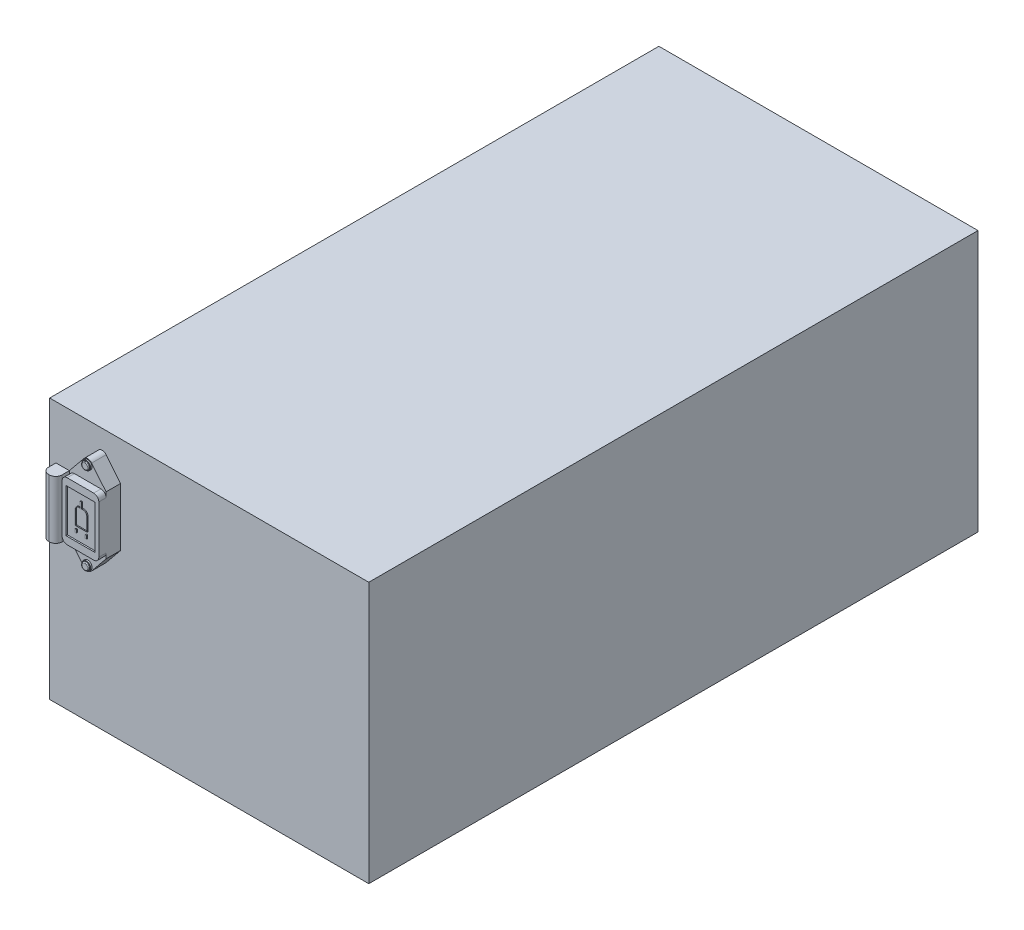
from build123d import *

# Parameters (mm, degrees)
SKETCH1_W           = 220
SKETCH1_H           = 180
BOSS_EXTRUDE1_DEPTH = 420
BOSS_EXTRUDE2_DEPTH = 10
BOSS_EXTRUDE3_DEPTH = 5
SKETCH4_R           = 3
BOSS_EXTRUDE4_DEPTH = 1
SKETCH5_R           = 2.5
BOSS_EXTRUDE5_DEPTH = 1
FILLET1_R           = 0.5
FILLET2_R           = 0.5
SKETCH6_W           = 20
SKETCH6_H           = 30
CUT_EXTRUDE1_DEPTH  = 1
SKETCH7_W           = 1
SKETCH7_H           = 2.143442922
BOSS_EXTRUDE6_DEPTH = 0.7
BOSS_EXTRUDE8_DEPTH = 40


with BuildPart() as part:
    # Sketch1 → Boss-Extrude1 (new body)
    with BuildSketch(Plane.XY):
        with Locations((110, 90)):
            Rectangle(SKETCH1_W, SKETCH1_H)
    extrude(amount=-BOSS_EXTRUDE1_DEPTH)

    # Sketch2 → Boss-Extrude2 (add)
    with BuildSketch(Plane.XY):
        with BuildLine():
            Line((23.564602078, 153.399638111), (33.506942996, 165.593075087))
            ThreePointArc((33.506942996, 165.593075087), (36.219508404, 166.881290985), (38.932073811, 165.593075087))
            Line((38.932073811, 165.593075087), (48.874414729, 153.399638111))
            Line((48.874414729, 153.399638111), (48.874414729, 113.399638111))
            Line((48.874414729, 113.399638111), (38.932073811, 101.206201136))
            ThreePointArc((38.932073811, 101.206201136), (36.219508404, 99.917985238), (33.506942996, 101.206201136))
            Line((33.506942996, 101.206201136), (23.564602078, 113.399638111))
            Line((23.564602078, 113.399638111), (23.564602078, 153.399638111))
        make_face()
    extrude(amount=BOSS_EXTRUDE2_DEPTH)

    # Sketch3 → Boss-Extrude3 (add)
    with BuildSketch(Plane.XY.offset(10)):
        with BuildLine():
            Line((27.064602078, 153.399638111), (45.374414729, 153.399638111))
            ThreePointArc((45.374414729, 153.399638111), (47.849288463, 152.374511846), (48.874414729, 149.899638111))
            Line((48.874414729, 149.899638111), (48.874414729, 116.899638111))
            ThreePointArc((48.874414729, 116.899638111), (47.849288463, 114.424764377), (45.374414729, 113.399638111))
            Line((45.374414729, 113.399638111), (27.064602078, 113.399638111))
            ThreePointArc((27.064602078, 113.399638111), (24.589728344, 114.424764377), (23.564602078, 116.899638111))
            Line((23.564602078, 116.899638111), (23.564602078, 149.899638111))
            ThreePointArc((23.564602078, 149.899638111), (24.589728344, 152.374511846), (27.064602078, 153.399638111))
        make_face()
    extrude(amount=BOSS_EXTRUDE3_DEPTH)

    # Sketch4 → Boss-Extrude4 (add)
    with BuildSketch(Plane.XY.offset(10)):
        with Locations((36.219508404, 163.381290985)):
            Circle(SKETCH4_R)
        with Locations((36.219508404, 103.417985238)):
            Circle(SKETCH4_R)
    extrude(amount=BOSS_EXTRUDE4_DEPTH)

    # Sketch5 → Boss-Extrude5 (add)
    with BuildSketch(Plane.XY.offset(11)):
        with Locations((36.219508404, 163.381290985)):
            Circle(SKETCH5_R)
        with Locations((36.219508404, 103.417985238)):
            Circle(SKETCH5_R)
    extrude(amount=BOSS_EXTRUDE5_DEPTH)

    # Fillet1
    fillet1_edges = [part.edges().sort_by_distance(p)[0] for p in [
        (33.719508404, 163.381290985, 12),
    ]]
    fillet(fillet1_edges, radius=FILLET1_R)

    # Fillet2
    fillet2_edges = [part.edges().sort_by_distance(p)[0] for p in [
        (33.719508404, 103.417985238, 12),
    ]]
    fillet(fillet2_edges, radius=FILLET2_R)

    # Sketch6 → Cut-Extrude1 (cut)
    with BuildSketch(Plane.XY.offset(15)):
        with Locations((36.219508404, 133.399638111)):
            Rectangle(SKETCH6_W, SKETCH6_H)
    extrude(amount=-CUT_EXTRUDE1_DEPTH, mode=Mode.SUBTRACT)

    # Sketch7 → Boss-Extrude6 (add)
    with BuildSketch(Plane.XY.offset(14)):
        with BuildLine():
            Line((36.756177122, 139.502564755), (37.804208618, 139.502564755))
            ThreePointArc((37.804208618, 139.502564755), (39.571975571, 138.770331708), (40.304208618, 137.002564755))
            Line((40.304208618, 137.002564755), (40.304208618, 127.296711468))
            Line((40.304208618, 127.296711468), (32.13480819, 127.296711468))
            Line((32.13480819, 127.296711468), (32.13480819, 137.002564755))
            ThreePointArc((32.13480819, 137.002564755), (32.867041237, 138.770331708), (34.63480819, 139.502564755))
            Line((34.63480819, 139.502564755), (35.682839685, 139.502564755))
            Line((35.682839685, 139.502564755), (35.682839685, 143.513382968))
            Line((35.682839685, 143.513382968), (36.756177122, 143.513382968))
            Line((36.756177122, 143.513382968), (36.756177122, 139.502564755))
        make_face()
        with BuildLine():
            Line((32.38480819, 127.546711468), (32.38480819, 137.002564755))
            ThreePointArc((32.38480819, 137.002564755), (33.043817932, 138.593555013), (34.63480819, 139.252564755))
            Line((34.63480819, 139.252564755), (35.932839685, 139.252564755))
            Line((35.932839685, 139.252564755), (36.506177122, 139.252564755))
            Line((36.506177122, 139.252564755), (37.804208618, 139.252564755))
            ThreePointArc((37.804208618, 139.252564755), (39.395198875, 138.593555013), (40.054208618, 137.002564755))
            Line((40.054208618, 137.002564755), (40.054208618, 127.546711468))
            Line((40.054208618, 127.546711468), (32.38480819, 127.546711468))
        make_face(mode=Mode.SUBTRACT)
        with Locations((32.63480819, 124.257038726)):
            Rectangle(SKETCH7_W, SKETCH7_H)
        with Locations((39.706049566, 124.257038726)):
            Rectangle(SKETCH7_W, SKETCH7_H)
    extrude(amount=BOSS_EXTRUDE6_DEPTH)


with BuildPart() as body_2:
    # Sketch8 → Boss-Extrude8 (new body)
    with BuildSketch(Plane(origin=(0, 153.399638111, 0), x_dir=(1, 0, 0), z_dir=(0, 1, 0))):
        with BuildLine():
            Line((23.564602078, -10), (14.33043312, -10))
            Line((14.33043312, -10), (14.33043312, -15.112636543))
            ThreePointArc((14.33043312, -15.112636543), (15.578080845, -18.124724601), (18.590168902, -19.372372325))
            Line((18.590168902, -19.372372325), (19.304866296, -19.372372325))
            ThreePointArc((19.304866296, -19.372372325), (22.316954354, -18.124724601), (23.564602078, -15.112636543))
            Line((23.564602078, -15.112636543), (23.564602078, -10))
        make_face()
    extrude(amount=-BOSS_EXTRUDE8_DEPTH)


solid = Compound([part.part, body_2.part])
